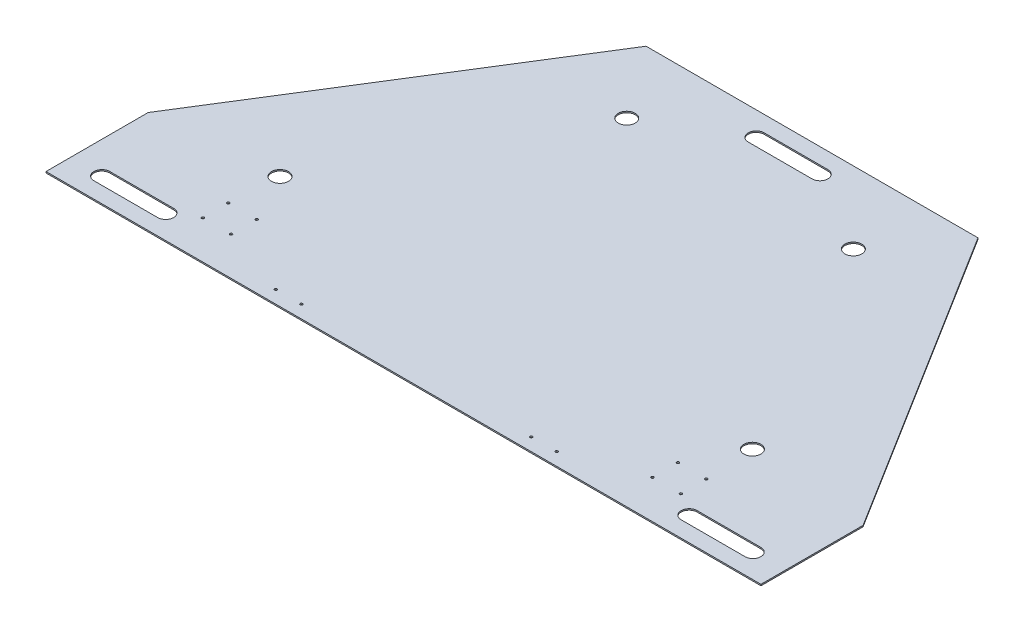
from build123d import *

# Parameters (mm, degrees)
BOSS_EXTRUDE1_DEPTH          = 2.65684
CUT_EXTRUDE1_DEPTH           = 3.65684
SKETCH3_R                    = 16.891
CUT_EXTRUDE2_DEPTH           = 3.65684
F_10_0_1935_DIAMETER_HOLE1_D = 4.9149


with BuildPart() as part:
    # Sketch1 → Boss-Extrude1 (new body)
    with BuildSketch(Plane(origin=(0, 0, 0), x_dir=(1, 0, 0), z_dir=(0, 1, 0))):
        Polygon((-711.2, 203.2), (-711.2, 0), (711.2, 0), (711.2, 203.2), (330.2, 812.8), (-330.2, 812.8), align=None)
    extrude(amount=BOSS_EXTRUDE1_DEPTH)

    # Sketch2 → Cut-Extrude1 (cut, through all)
    with BuildSketch(Plane(origin=(0, 2.65684, 0), x_dir=(1, 0, 0), z_dir=(0, 1, 0))):
        with BuildLine():
            Line((-63.5, 781.05), (63.5, 781.05))
            ThreePointArc((63.5, 781.05), (79.375, 765.175), (63.5, 749.3))
            Line((63.5, 749.3), (-63.5, 749.3))
            ThreePointArc((-63.5, 749.3), (-79.375, 765.175), (-63.5, 781.05))
        make_face()
        with BuildLine():
            Line((-647.7, 63.5), (-520.7, 63.5))
            ThreePointArc((-520.7, 63.5), (-504.825, 47.625), (-520.7, 31.75))
            Line((-520.7, 31.75), (-647.7, 31.75))
            ThreePointArc((-647.7, 31.75), (-663.575, 47.625), (-647.7, 63.5))
        make_face()
        with BuildLine():
            Line((520.7, 63.5), (647.7, 63.5))
            ThreePointArc((647.7, 63.5), (663.575, 47.625), (647.7, 31.75))
            Line((647.7, 31.75), (520.7, 31.75))
            ThreePointArc((520.7, 31.75), (504.825, 47.625), (520.7, 63.5))
        make_face()
    extrude(amount=-CUT_EXTRUDE1_DEPTH, mode=Mode.SUBTRACT)

    # Sketch3 → Cut-Extrude2 (cut, through all)
    with BuildSketch(Plane(origin=(0, 2.65684, 0), x_dir=(1, 0, 0), z_dir=(0, 1, 0))):
        with Locations((-469.9, 224.282)):
            Circle(SKETCH3_R)
        with Locations((-225.425, 669.586361505)):
            Circle(SKETCH3_R)
        with Locations((225.425, 669.586361505)):
            Circle(SKETCH3_R)
        with Locations((469.9, 224.282)):
            Circle(SKETCH3_R)
    extrude(amount=-CUT_EXTRUDE2_DEPTH, mode=Mode.SUBTRACT)

    # #10 (0.1935) Diameter Hole1 (through all)
    with Locations(Plane(origin=(0, 2.65684, 0), x_dir=(1, 0, 0), z_dir=(0, 1, 0))):
        with Locations((228.6, 25.4), (279.4, 25.4), (419.1, 76.2), (419.1, 127), (475.488, 76.2), (475.488, 127), (-475.488, 127), (-475.488, 76.2), (-419.1, 76.2), (-419.1, 127), (-279.4, 25.4), (-228.6, 25.4)):
            Hole(F_10_0_1935_DIAMETER_HOLE1_D / 2)


solid = part.part
